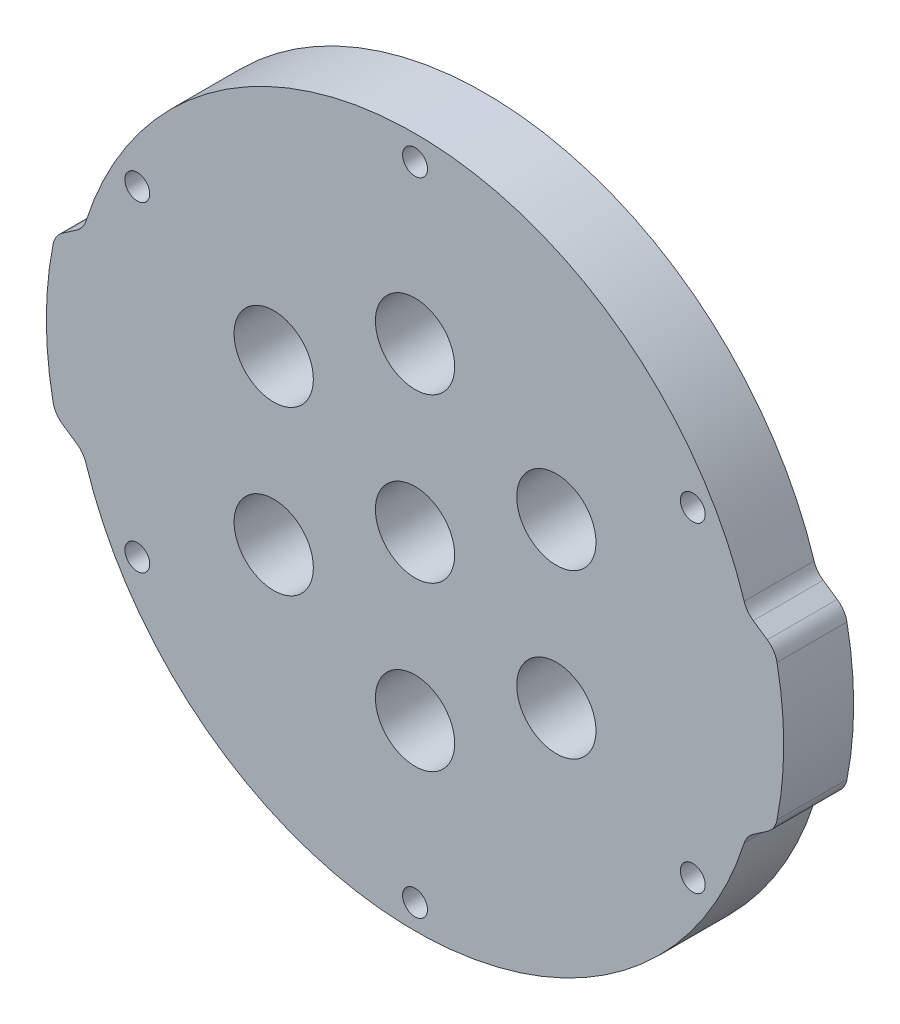
from build123d import *

# Parameters (mm, degrees)
SKETCH1_R           = 1.6
BOSS_EXTRUDE1_DEPTH = 9
FILLET1_R           = 3
SKETCH2_R           = 5.1
CUT_EXTRUDE1_DEPTH  = 10


with BuildPart() as part:
    # Sketch1 → Boss-Extrude1 (new body)
    with BuildSketch(Plane.XY):
        with BuildLine():
            Line((-46.324821937, 10), (-42.656212912, 12.5))
            ThreePointArc((-42.656212912, 12.5), (0, 44.45), (42.656212912, 12.5))
            Line((42.656212912, 12.5), (46.324821937, 10))
            ThreePointArc((46.324821937, 10), (47.45, 0), (46.324821937, -10))
            Line((46.324821937, -10), (42.656212912, -12.5))
            ThreePointArc((42.656212912, -12.5), (0, -44.45), (-42.656212912, -12.5))
            Line((-42.656212912, -12.5), (-46.324821937, -10))
            ThreePointArc((-46.324821937, -10), (-47.45, 0), (-46.324821937, 10))
        make_face()
        with Locations((0, 41.275)):
            Circle(SKETCH1_R, mode=Mode.SUBTRACT)
        with Locations((35.745198541, 20.6375)):
            Circle(SKETCH1_R, mode=Mode.SUBTRACT)
        with Locations((35.745198541, -20.6375)):
            Circle(SKETCH1_R, mode=Mode.SUBTRACT)
        with Locations((0, -41.275)):
            Circle(SKETCH1_R, mode=Mode.SUBTRACT)
        with Locations((-35.745198541, -20.6375)):
            Circle(SKETCH1_R, mode=Mode.SUBTRACT)
        with Locations((-35.745198541, 20.6375)):
            Circle(SKETCH1_R, mode=Mode.SUBTRACT)
    extrude(amount=BOSS_EXTRUDE1_DEPTH)

    # Fillet1
    fillet1_edges = [part.edges().sort_by_distance(p)[0] for p in [
        (46.324821937, -10, 4.5),
        (42.656212912, -12.5, 4.5),
        (-42.656212912, -12.5, 4.5),
        (-46.324821937, -10, 4.5),
        (-46.324821937, 10, 4.5),
        (-42.656212912, 12.5, 4.5),
        (42.656212912, 12.5, 4.5),
        (46.324821937, 10, 4.5),
    ]]
    fillet(fillet1_edges, radius=FILLET1_R)

    # Sketch2 → Cut-Extrude1 (cut, through all)
    with BuildSketch(Plane.XY.offset(9)):
        with Locations((0, 21)):
            Circle(SKETCH2_R)
        with Locations((18.186533479, 10.5)):
            Circle(SKETCH2_R)
        with Locations((18.186533479, -10.5)):
            Circle(SKETCH2_R)
        with Locations((0, -21)):
            Circle(SKETCH2_R)
        with Locations((-18.186533479, -10.5)):
            Circle(SKETCH2_R)
        with Locations((-18.186533479, 10.5)):
            Circle(SKETCH2_R)
        Circle(SKETCH2_R)
    extrude(amount=-CUT_EXTRUDE1_DEPTH, mode=Mode.SUBTRACT)


solid = part.part
